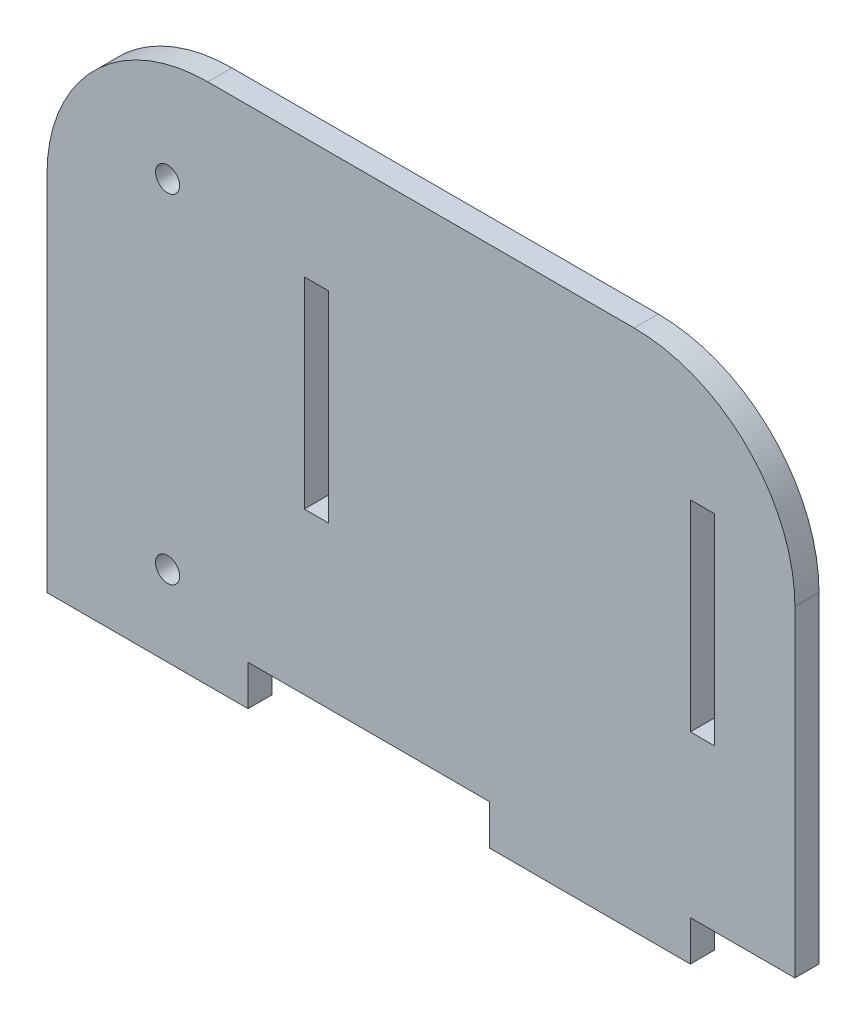
from build123d import *

# Parameters (mm, degrees)
RESSALTO_EXTRUS_O1_DEPTH = 3
ESBO_O2_R                = 1.5
CORTE_EXTRUS_O1_DEPTH    = 10
ESBO_O3_W                = 3
ESBO_O3_H                = 25
CORTE_EXTRUS_O2_DEPTH    = 10


with BuildPart() as part:
    # Esboço1 → Ressalto-extrusão1 (new body)
    with BuildSketch(Plane.XY):
        with BuildLine():
            Line((43.040081042, -11.381695114), (56.040081042, -11.381695114))
            Line((56.040081042, -11.381695114), (56.040081042, 28.618304886))
            ThreePointArc((56.040081042, 28.618304886), (50.182216666, 42.76044051), (36.040081042, 48.618304886))
            Line((36.040081042, 48.618304886), (-16.959918958, 48.618304886))
            ThreePointArc((-16.959918958, 48.618304886), (-31.102054581, 42.76044051), (-36.959918958, 28.618304886))
            Line((-36.959918958, 28.618304886), (-36.959918958, -1.381695114))
            Line((-36.959918958, -1.381695114), (-36.959918958, -16.381695114))
            Line((-36.959918958, -16.381695114), (-11.959918958, -16.381695114))
            Line((-11.959918958, -16.381695114), (-11.959918958, -11.381695114))
            Line((-11.959918958, -11.381695114), (18.040081042, -11.381695114))
            Line((18.040081042, -11.381695114), (18.040081042, -16.381695114))
            Line((18.040081042, -16.381695114), (43.040081042, -16.381695114))
            Line((43.040081042, -16.381695114), (43.040081042, -11.381695114))
        make_face()
    extrude(amount=RESSALTO_EXTRUS_O1_DEPTH)

    # Esboço2 → Corte-extrusão1 (cut)
    with BuildSketch(Plane(origin=(0, 0, 0), x_dir=(-1, 0, 0), z_dir=(0, 0, -1))):
        with Locations((21.959918958, 35.668304886)):
            Circle(ESBO_O2_R)
        with Locations((21.959918958, -6.381695114)):
            Circle(ESBO_O2_R)
    extrude(amount=-CORTE_EXTRUS_O1_DEPTH, mode=Mode.SUBTRACT)

    # Esboço3 → Corte-extrusão2 (cut)
    with BuildSketch(Plane.XY.offset(3)):
        with Locations((-3.459918958, 21.118304886)):
            Rectangle(ESBO_O3_W, ESBO_O3_H)
        with Locations((44.540081042, 21.118304886)):
            Rectangle(ESBO_O3_W, ESBO_O3_H)
    extrude(amount=-CORTE_EXTRUS_O2_DEPTH, mode=Mode.SUBTRACT)


solid = part.part
